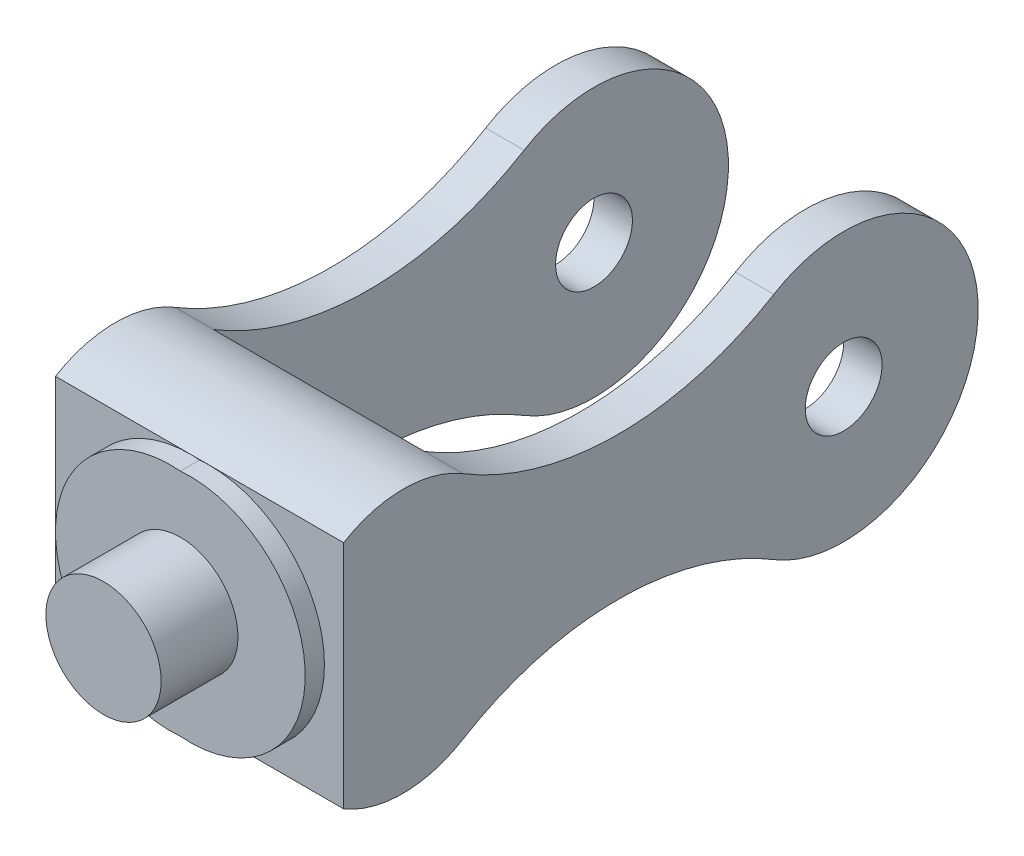
from build123d import *

# Parameters (mm, degrees)
SKETCH1_R           = 30
BOSS_EXTRUDE1_DEPTH = 5
BOSS_EXTRUDE2_DEPTH = 10
BOSS_EXTRUDE3_DEPTH = 55
SKETCH4_R           = 15
BOSS_EXTRUDE4_DEPTH = 20
SKETCH5_R           = 10
CUT_EXTRUDE1_DEPTH  = 10


with BuildPart() as part:
    # Sketch1 → Boss-Extrude1 (new body)
    with BuildSketch(Plane.XY):
        Circle(SKETCH1_R)
    extrude(amount=BOSS_EXTRUDE1_DEPTH)



with BuildPart() as body_2:
    # Sketch2 → Boss-Extrude2 (new body)
    with BuildSketch(Plane(origin=(30, 0, 0), x_dir=(0, 0, -1), z_dir=(1, 0, 0))):
        with BuildLine():
            Line((0, 30), (0, -30))
            ThreePointArc((0, -30), (15.578718077, -34.24908425), (31.103401006, -29.80663067))
            ThreePointArc((31.103401006, -29.80663067), (71.537822314, -18.507886831), (111.972243623, -29.80663067))
            ThreePointArc((111.972243623, -29.80663067), (165.159924398, 0.096684665), (111.972243623, 30))
            ThreePointArc((111.972243623, 30), (71.537822314, 18.701256161), (31.103401006, 30))
            ThreePointArc((31.103401006, 30), (15.551700503, 34.345670707), (0, 30))
        make_face()
    extrude(amount=BOSS_EXTRUDE2_DEPTH)


with BuildPart() as part_1:
    add(part.part)

    add(body_2.part)  # Boss-Extrude3 merges body 2
    # Sketch3 → Boss-Extrude3 (add)
    with BuildSketch(Plane.ZY.offset(-30)):
        with BuildLine():
            Line((-31.103401006, 30), (-31.103401006, -29.80663067))
            ThreePointArc((-31.103401006, -29.80663067), (-15.578718077, -34.24908425), (0, -30))
            Line((0, -30), (0, 30))
            ThreePointArc((0, 30), (-15.551700503, 34.345670707), (-31.103401006, 30))
        make_face()
    extrude(amount=BOSS_EXTRUDE3_DEPTH)

    # Mirror1: part across plane


with BuildPart() as part_2:
    add(part_1.part)
    add(part_1.part.mirror(Plane.ZY.offset(-2.5)))

    # Sketch4 → Boss-Extrude4 (add)
    with BuildSketch(Plane.XY.offset(5)):
        with Locations((2.5, 0)):
            Circle(SKETCH4_R)
    extrude(amount=BOSS_EXTRUDE4_DEPTH)

    # Sketch5 → Cut-Extrude1 (cut)
    with BuildSketch(Plane.ZY.offset(-30)):
        with Locations((-130.159924398, 0.096684665)):
            Circle(SKETCH5_R)
    cut_extrude1 = extrude(amount=-CUT_EXTRUDE1_DEPTH, mode=Mode.SUBTRACT)

    # Mirror2: Cut-Extrude1 across plane
    add(cut_extrude1.mirror(Plane.ZY.offset(-2.5)), mode=Mode.SUBTRACT)


solid = part_2.part
